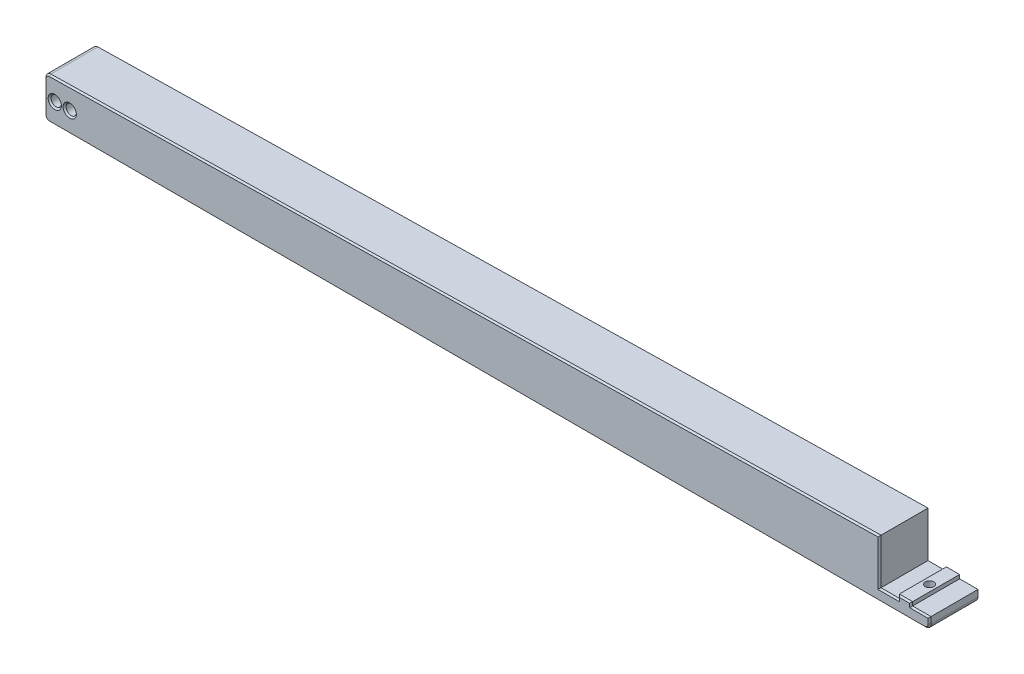
from build123d import *

# Parameters (mm, degrees)
SKETCH1_R           = 2.05
BOSS_EXTRUDE1_DEPTH = 20
SKETCH2_R           = 1.7
CUT_EXTRUDE1_DEPTH  = 20
SKETCH3_R           = 2.8
CUT_EXTRUDE2_DEPTH  = 2
FILLET1_R           = 2
CHAMFER1_SIZE       = 0.6
CHAMFER2_SIZE       = 0.6


with BuildPart() as part:
    # Sketch1 → Boss-Extrude1 (new body)
    with BuildSketch(Plane.XY):
        Polygon((15.2, -92.57905153), (15.2, -76.05265525), (349.336279792, -69.740004959), (349.336279792, -87.940004959), (356.686279792, -87.940004959), (356.686279792, -86.440004959), (361.986279792, -86.440004959), (361.986279792, -87.940004959), (369.336279792, -87.940004959), (369.336279792, -92.57905153), align=None)
        with Locations((25.300294751, -84.31585339)):
            Circle(SKETCH1_R, mode=Mode.SUBTRACT)
        with Locations((19.300294751, -84.31585339)):
            Circle(SKETCH1_R, mode=Mode.SUBTRACT)
    extrude(amount=BOSS_EXTRUDE1_DEPTH)

    # Sketch2 → Cut-Extrude1 (cut)
    with BuildSketch(Plane(origin=(0, -92.57905153, 0), x_dir=(-1, 0, 0), z_dir=(0, -1, 0))):
        with Locations((-359.336279792, -10)):
            Circle(SKETCH2_R)
    extrude(amount=-CUT_EXTRUDE1_DEPTH, mode=Mode.SUBTRACT)

    # Sketch3 → Cut-Extrude2 (cut)
    with BuildSketch(Plane.XZ.offset(92.57905153)):
        with Locations((359.336279792, 10)):
            Circle(SKETCH3_R)
    extrude(amount=-CUT_EXTRUDE2_DEPTH, mode=Mode.SUBTRACT)

    # Fillet1
    fillet1_edges = [part.edges().sort_by_distance(p)[0] for p in [
        (15.2, -92.57905153, 10),
        (15.2, -76.05265525, 10),
        (369.336279792, -92.57905153, 10),
    ]]
    fillet(fillet1_edges, radius=FILLET1_R)

    # Chamfer1
    chamfer1_edges = [part.edges().sort_by_distance(p)[0] for p in [
        (183.249250825, -72.877794523, 0),
        (349.336279792, -78.840004959, 0),
        (353.011279792, -87.940004959, 0),
        (356.686279792, -87.190004959, 0),
        (359.336279792, -86.440004959, 0),
        (361.986279792, -87.190004959, 0),
        (365.661279792, -87.940004959, 0),
        (23.250294751, -84.31585339, 0),
        (17.250294751, -84.31585339, 0),
        (369.336279792, -89.259528244, 0),
        (192.268139896, -92.57905153, 0),
        (15.2, -84.297139394, 0),
        (15.785786438, -91.993265092, 0),
        (15.772492332, -76.614433962, 0),
        (368.750493354, -91.993265092, 0),
    ]]
    chamfer(chamfer1_edges, length=CHAMFER1_SIZE)

    # Chamfer2
    chamfer2_edges = [part.edges().sort_by_distance(p)[0] for p in [
        (365.661279792, -87.940004959, 20),
        (361.986279792, -87.190004959, 20),
        (359.336279792, -86.440004959, 20),
        (356.686279792, -87.190004959, 20),
        (23.250294751, -84.31585339, 20),
        (353.011279792, -87.940004959, 20),
        (17.250294751, -84.31585339, 20),
        (349.336279792, -78.840004959, 20),
        (183.249250825, -72.877794523, 20),
        (369.336279792, -89.259528244, 20),
        (192.268139896, -92.57905153, 20),
        (15.2, -84.297139394, 20),
        (15.785786438, -91.993265092, 20),
        (15.772492332, -76.614433962, 20),
        (368.750493354, -91.993265092, 20),
    ]]
    chamfer(chamfer2_edges, length=CHAMFER2_SIZE)


solid = part.part
